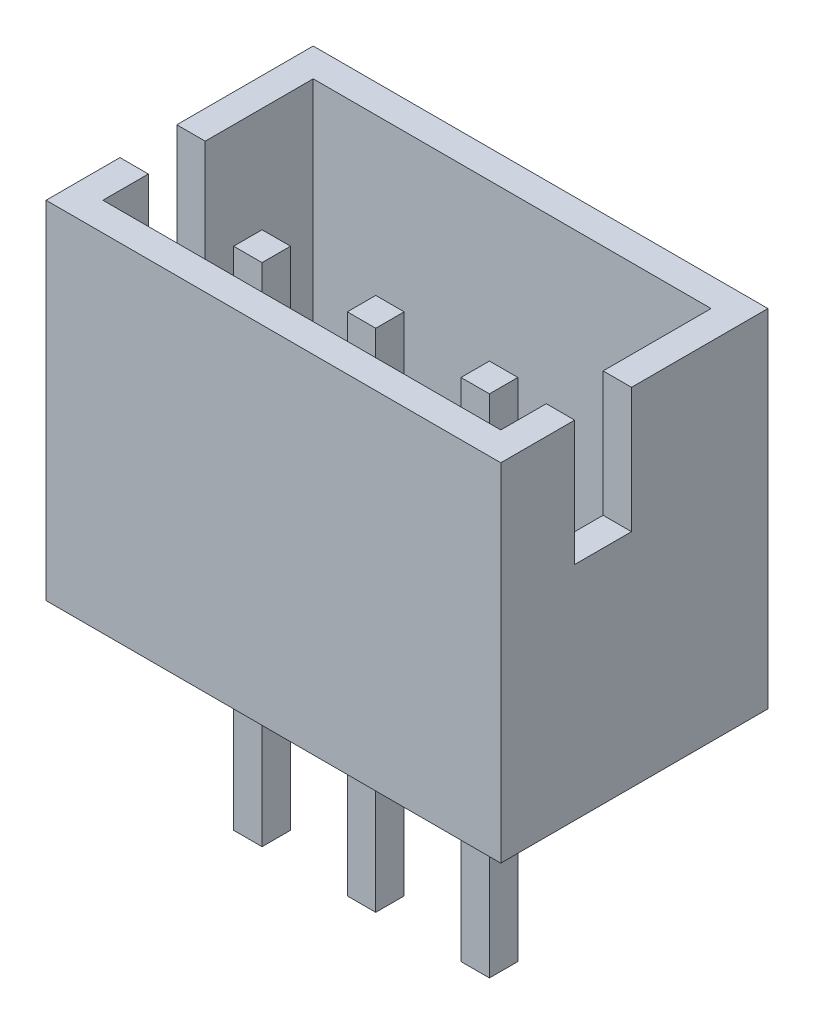
from build123d import *

# Parameters (mm, degrees)
SKETCH1_W                  = 8
SKETCH1_H                  = 4.7
BOSS_EXTRUDE1_DEPTH        = 6.1
SHELL1_T                   = -0.5
SKETCH2_W                  = 0.5
SKETCH2_H                  = 0.5
BOSS_EXTRUDE2_DEPTH        = 5
BOSS_EXTRUDE2_DEPTH_BACK   = 3.9
BOSS_EXTRUDE2_2_DEPTH      = 5
BOSS_EXTRUDE2_2_DEPTH_BACK = 3.9
BOSS_EXTRUDE2_3_DEPTH      = 5
BOSS_EXTRUDE2_3_DEPTH_BACK = 3.9
SKETCH3_W                  = 1
SKETCH3_H                  = 2.2
CUT_EXTRUDE1_DEPTH         = 7.5


with BuildPart() as part:
    # Sketch1 → Boss-Extrude1 (new body)
    with BuildSketch(Plane(origin=(0, 0, 0), x_dir=(1, 0, 0), z_dir=(0, 1, 0))):
        Rectangle(SKETCH1_W, SKETCH1_H)
    extrude(amount=BOSS_EXTRUDE1_DEPTH)

    # Shell1
    shell1_openings = [part.faces().sort_by_distance(p)[0] for p in [
        (0, 6.1, 0),
    ]]
    offset(amount=SHELL1_T, openings=shell1_openings, kind=Kind.INTERSECTION)

    # Sketch3 → Cut-Extrude1 (cut)
    with BuildSketch(Plane.ZY.offset(4)):
        with Locations((0.55, 5)):
            Rectangle(SKETCH3_W, SKETCH3_H)
    cut_extrude1 = extrude(amount=-CUT_EXTRUDE1_DEPTH, mode=Mode.SUBTRACT)

    # Mirror1: Cut-Extrude1 across plane
    add(cut_extrude1.mirror(Plane(origin=(0, 0, 0), x_dir=(0, 0, 1), z_dir=(1, 0, 0))), mode=Mode.SUBTRACT)


with BuildPart() as body_2:
    # Sketch2 → Boss-Extrude2 (new body, two sides)
    with BuildSketch(Plane(origin=(0, 0.5, 0), x_dir=(1, 0, 0), z_dir=(0, 1, 0))) as boss_extrude2_sk:
        with Locations((0, -0.55)):
            Rectangle(SKETCH2_W, SKETCH2_H)
    extrude(amount=BOSS_EXTRUDE2_DEPTH)
    extrude(boss_extrude2_sk.sketch, amount=-BOSS_EXTRUDE2_DEPTH_BACK)


with BuildPart() as body_3:
    # Sketch2 → Boss-Extrude2 2 (new body, two sides)
    with BuildSketch(Plane(origin=(0, 0.5, 0), x_dir=(1, 0, 0), z_dir=(0, 1, 0))) as boss_extrude2_2_sk:
        with Locations((-2, -0.55)):
            Rectangle(SKETCH2_W, SKETCH2_H)
    extrude(amount=BOSS_EXTRUDE2_2_DEPTH)
    extrude(boss_extrude2_2_sk.sketch, amount=-BOSS_EXTRUDE2_2_DEPTH_BACK)


with BuildPart() as body_4:
    # Sketch2 → Boss-Extrude2 3 (new body, two sides)
    with BuildSketch(Plane(origin=(0, 0.5, 0), x_dir=(1, 0, 0), z_dir=(0, 1, 0))) as boss_extrude2_3_sk:
        with Locations((2, -0.55)):
            Rectangle(SKETCH2_W, SKETCH2_H)
    extrude(amount=BOSS_EXTRUDE2_3_DEPTH)
    extrude(boss_extrude2_3_sk.sketch, amount=-BOSS_EXTRUDE2_3_DEPTH_BACK)


solid = Compound([part.part, body_2.part, body_3.part, body_4.part])
